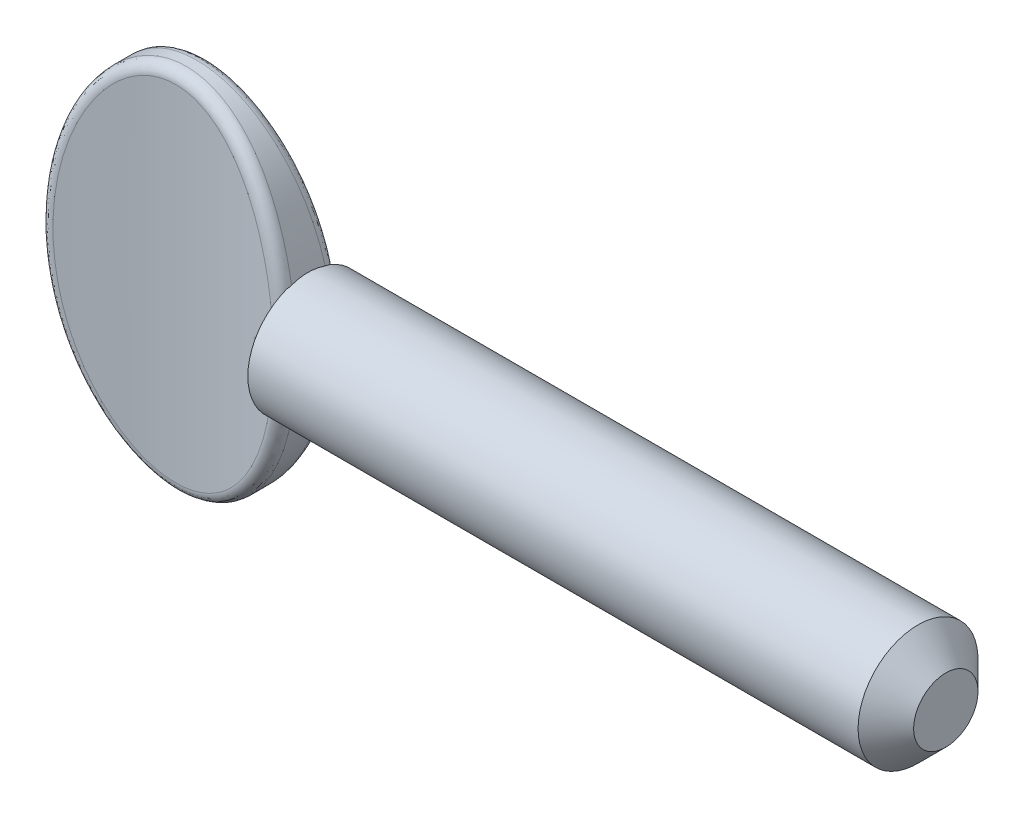
from build123d import *

# Parameters (mm, degrees)
SKETCH1_RX              = 7.366
SKETCH1_RY              = 4.953
EXTRUDE1_DEPTH          = 1.27
CUT_EXTRUDE1_DEPTH      = 9.966775619
CUT_EXTRUDE1_DEPTH_BACK = 9.966775619
SKETCH2_OUTSIDE_W       = 15.492
SKETCH2_OUTSIDE_H       = 8.126
FILLET3_R               = 0.423333333


with BuildPart() as part:
    # Sketch1 → Extrude1 (new, symmetric)
    with BuildSketch(Plane.XY):
        with Locations(Location((0, 0), (0, 0, -90))):
            Ellipse(SKETCH1_RX, SKETCH1_RY)
    extrude(amount=EXTRUDE1_DEPTH, both=True)

    # Sketch2 outside → Cut-Extrude1 (cut, two sides: drawn at the far end of the back side and taken through both)
    with BuildSketch(Plane(origin=(0, 0, 0), x_dir=(1, 0, 0), z_dir=(0, 1, 0)).offset(-CUT_EXTRUDE1_DEPTH_BACK)):
        Rectangle(SKETCH2_OUTSIDE_W, SKETCH2_OUTSIDE_H)
        with BuildLine():
            Line((-4.953, 1.27), (-4.953, -1.27))
            ThreePointArc((-4.953, -1.27), (0, -0.635), (4.953, -1.27))
            Line((4.953, -1.27), (4.953, 1.27))
            ThreePointArc((4.953, 1.27), (0, 0.635), (-4.953, 1.27))
        make_face(mode=Mode.SUBTRACT)
    extrude(amount=CUT_EXTRUDE1_DEPTH + CUT_EXTRUDE1_DEPTH_BACK, mode=Mode.SUBTRACT)

    # Fillet3
    fillet3_edges = [part.edges().sort_by_distance(p)[0] for p in [
        (-3.813290219, -4.700763975, 1.008861807),
        (5.6e-08, 7.366, -0.635),
    ]]
    fillet(fillet3_edges, radius=FILLET3_R)

    # Sketch3 → Revolve1 (revolve)
    with BuildSketch(Plane(origin=(0, 0, 0), x_dir=(1, 0, 0), z_dir=(0, 1, 0))):
        with BuildLine():
            Line((30.353, 0), (30.353, 1.2954))
            Line((30.353, 1.2954), (29.2354, 2.413))
            Line((29.2354, 2.413), (6.604, 2.413))
            Line((6.604, 2.413), (4.679699868, 2.413))
            ThreePointArc((4.679699868, 2.413), (4.330494414, 1.452158546), (3.445852664, 0.93974297))
            Line((3.445852664, 0.93974297), (3.445852664, 0))
            Line((3.445852664, 0), (30.353, 0))
        make_face()
    revolve(axis=Axis((0, 0, 0), (1, 0, 0)))


solid = part.part
